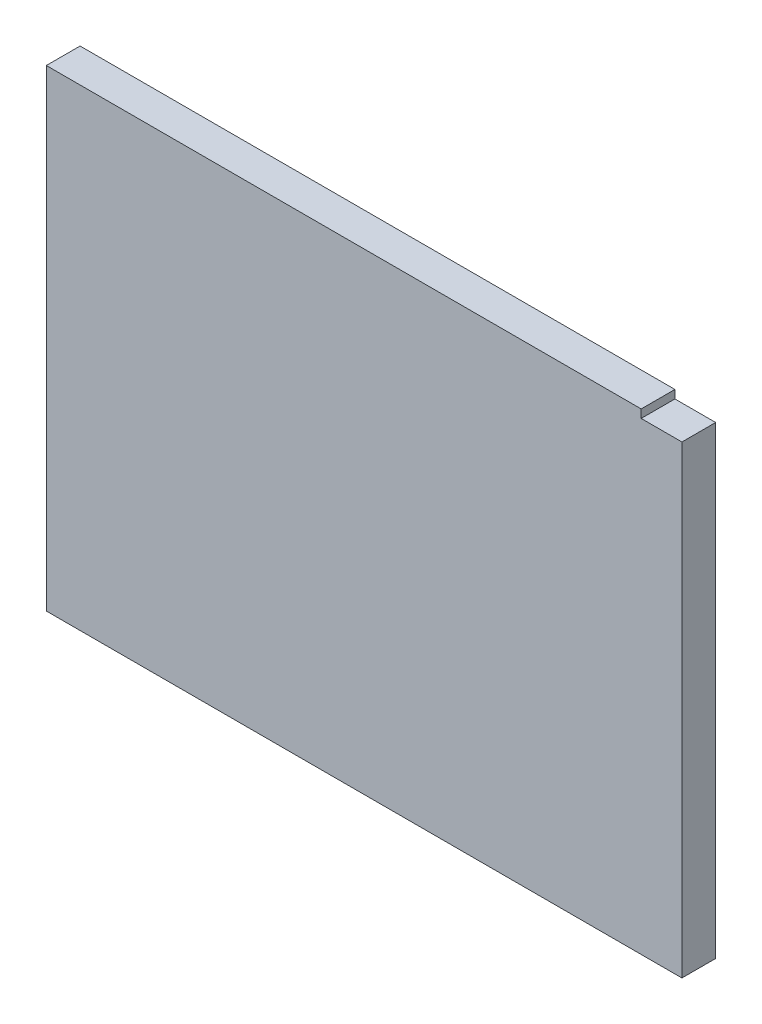
from build123d import *

# Parameters (mm, degrees)
SIDEOUTLINE_W               = 215.265
SIDEOUTLINE_H               = 160.02
SIDEOUTLINE_THICKNESS_DEPTH = 11.43
SKETCH2_W                   = 13.79855
SKETCH2_H                   = 2.794
CUT_EXTRUDE1_DEPTH          = 11.43


with BuildPart() as part:
    # SideOutline → SideOutline_Thickness (new body)
    with BuildSketch(Plane.XY):
        with Locations((-4870.7675, 1299.21)):
            Rectangle(SIDEOUTLINE_W, SIDEOUTLINE_H)
    extrude(amount=-SIDEOUTLINE_THICKNESS_DEPTH)

    # Sketch2 → Cut-Extrude1 (cut)
    with BuildSketch(Plane(origin=(0, 0, -11.43), x_dir=(-1, 0, 0), z_dir=(0, 0, -1))):
        with Locations((4770.034275, 1377.823)):
            Rectangle(SKETCH2_W, SKETCH2_H)
    extrude(amount=-CUT_EXTRUDE1_DEPTH, mode=Mode.SUBTRACT)


solid = part.part
